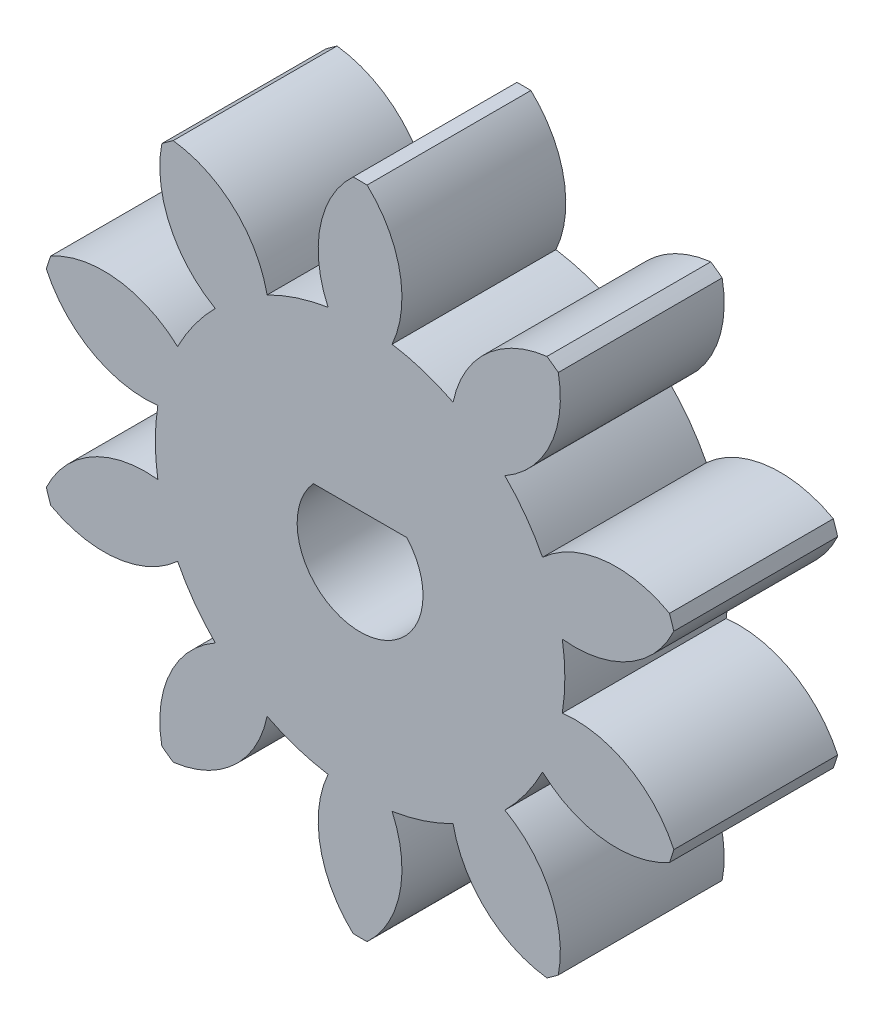
from build123d import *

# Parameters (mm, degrees)
SKETCH4_R           = 2
BOSS_EXTRUDE3_DEPTH = 6
SKETCH6_R           = 3.276903459
BOSS_EXTRUDE4_DEPTH = 6
CUT_EXTRUDE2_DEPTH  = 10


with BuildPart() as part:
    # Sketch4 → Boss-Extrude3 (new body)
    with BuildSketch(Plane.XY):
        with BuildLine():
            ThreePointArc((11.330682707, 3.9516616), (8.917819898, 4.428819506), (6.681915604, 3.403968986))
            ThreePointArc((6.681915604, 3.403968986), (6.066818441, 4.407801607), (5.302192362, 5.302995112))
            ThreePointArc((5.302192362, 5.302995112), (6.967815552, 7.112770233), (7.259627029, 9.554989032))
            ThreePointArc((7.259627029, 9.554989032), (7.053423028, 9.708203932), (6.843986457, 9.856969584))
            ThreePointArc((6.843986457, 9.856969584), (4.61147306, 8.824753264), (3.40498051, 6.681400208))
            ThreePointArc((3.40498051, 6.681400208), (2.317318441, 7.131972816), (1.172541409, 7.406763642))
            ThreePointArc((1.172541409, 7.406763642), (1.456299749, 9.849931218), (0.256880001, 11.997250213))
            ThreePointArc((0.256880001, 11.997250213), (0, 12), (-0.256880001, 11.997250213))
            ThreePointArc((-0.256880001, 11.997250213), (-1.456299749, 9.849931218), (-1.172541409, 7.406763642))
            ThreePointArc((-1.172541409, 7.406763642), (-2.317318441, 7.131972816), (-3.404980509, 6.681400207))
            ThreePointArc((-3.404980509, 6.681400207), (-4.61147306, 8.824753264), (-6.843986457, 9.856969584))
            ThreePointArc((-6.843986457, 9.856969584), (-7.053423028, 9.708203933), (-7.259627029, 9.554989032))
            ThreePointArc((-7.259627029, 9.554989032), (-6.967815552, 7.112770233), (-5.302192362, 5.302995112))
            ThreePointArc((-5.302192362, 5.302995112), (-6.066818441, 4.407801607), (-6.681915604, 3.403968986))
            ThreePointArc((-6.681915604, 3.403968986), (-8.917819898, 4.428819506), (-11.330682707, 3.9516616))
            ThreePointArc((-11.330682707, 3.9516616), (-11.412678196, 3.708203933), (-11.489443278, 3.463046803))
            ThreePointArc((-11.489443278, 3.463046803), (-9.817862641, 1.658772773), (-7.406586048, 1.173662691))
            ThreePointArc((-7.406586048, 1.173662691), (-7.499, 0), (-7.406586048, -1.173662691))
            ThreePointArc((-7.406586048, -1.173662691), (-9.817862641, -1.658772773), (-11.489443278, -3.463046803))
            ThreePointArc((-11.489443278, -3.463046803), (-11.412678196, -3.708203933), (-11.330682707, -3.9516616))
            ThreePointArc((-11.330682707, -3.9516616), (-8.917819898, -4.428819506), (-6.681915604, -3.403968986))
            ThreePointArc((-6.681915604, -3.403968986), (-6.066818441, -4.407801607), (-5.302192362, -5.302995112))
            ThreePointArc((-5.302192362, -5.302995112), (-6.967815552, -7.112770233), (-7.259627029, -9.554989032))
            ThreePointArc((-7.259627029, -9.554989032), (-7.053423028, -9.708203932), (-6.843986457, -9.856969584))
            ThreePointArc((-6.843986457, -9.856969584), (-4.61147306, -8.824753264), (-3.404980509, -6.681400207))
            ThreePointArc((-3.404980509, -6.681400207), (-2.317318441, -7.131972816), (-1.172541409, -7.406763642))
            ThreePointArc((-1.172541409, -7.406763642), (-1.456299749, -9.849931218), (-0.256880001, -11.997250213))
            ThreePointArc((-0.256880001, -11.997250213), (0, -12), (0.256880001, -11.997250213))
            ThreePointArc((0.256880001, -11.997250213), (1.456299749, -9.849931218), (1.172541409, -7.406763642))
            ThreePointArc((1.172541409, -7.406763642), (2.317318441, -7.131972816), (3.404980509, -6.681400207))
            ThreePointArc((3.404980509, -6.681400207), (4.61147306, -8.824753264), (6.843986457, -9.856969584))
            ThreePointArc((6.843986457, -9.856969584), (7.053423027, -9.708203933), (7.259627029, -9.554989032))
            ThreePointArc((7.259627029, -9.554989032), (6.967815552, -7.112770233), (5.302192362, -5.302995112))
            ThreePointArc((5.302192362, -5.302995112), (6.066818441, -4.407801607), (6.681915604, -3.403968986))
            ThreePointArc((6.681915604, -3.403968986), (8.917819898, -4.428819506), (11.330682707, -3.9516616))
            ThreePointArc((11.330682707, -3.9516616), (11.412678196, -3.708203932), (11.489443278, -3.463046803))
            ThreePointArc((11.489443278, -3.463046803), (9.817862641, -1.658772773), (7.406586048, -1.173662691))
            ThreePointArc((7.406586048, -1.173662691), (7.499, 0), (7.406586048, 1.173662691))
            ThreePointArc((7.406586048, 1.173662691), (9.817862641, 1.658772773), (11.489443278, 3.463046803))
            ThreePointArc((11.489443278, 3.463046803), (11.412678196, 3.708203932), (11.330682707, 3.9516616))
        make_face()
        Circle(SKETCH4_R, mode=Mode.SUBTRACT)
    extrude(amount=BOSS_EXTRUDE3_DEPTH)

    # Sketch6 → Boss-Extrude4 (add)
    with BuildSketch(Plane.XY.offset(6)):
        Circle(SKETCH6_R)
    extrude(amount=-BOSS_EXTRUDE4_DEPTH)

    # Sketch7 → Cut-Extrude2 (cut)
    with BuildSketch(Plane.XY.offset(6)):
        with BuildLine():
            Line((-1.710555465, 1.545), (1.710555465, 1.545))
            ThreePointArc((1.710555465, 1.545), (0, -2.305), (-1.710555465, 1.545))
        make_face()
    extrude(amount=-CUT_EXTRUDE2_DEPTH, mode=Mode.SUBTRACT)


solid = part.part
